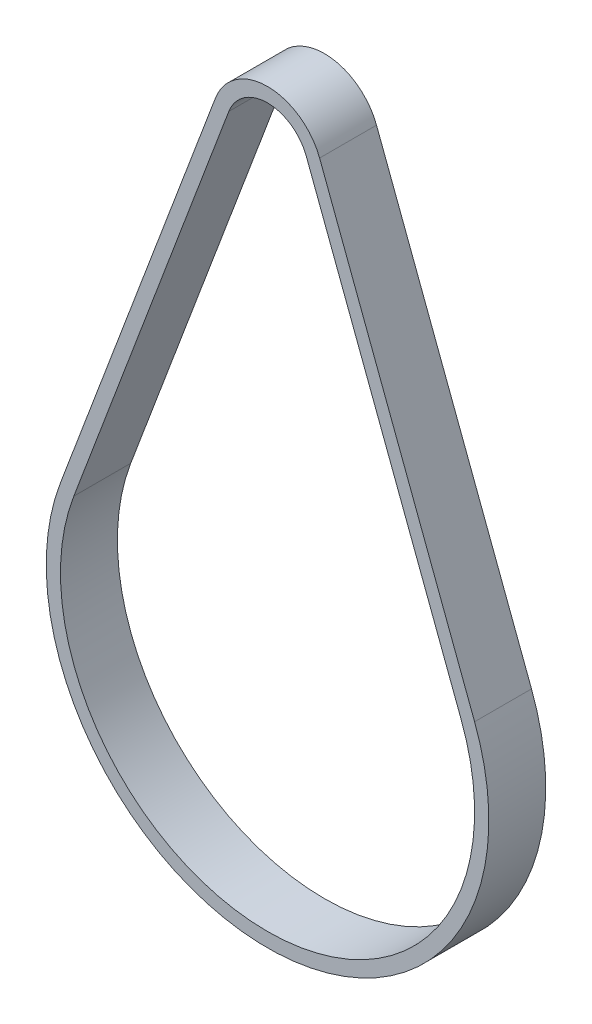
from build123d import *

# Parameters (mm, degrees)
SALIENTE_EXTRUIR1_DEPTH = 8


with BuildPart() as part:
    # Croquis1 → Saliente-Extruir1 (new body)
    with BuildSketch(Plane.XY):
        with BuildLine():
            Line((-7.316283488, 29.567625694), (-29.101406381, -28.155231387))
            ThreePointArc((-29.101406381, -28.155231387), (0, -70.243362618), (29.101406381, -28.155231387))
            Line((29.101406381, -28.155231387), (7.316283488, 29.567625694))
            ThreePointArc((7.316283488, 29.567625694), (0, 34.626394823), (-7.316283488, 29.567625694))
        make_face()
        with BuildLine():
            Line((-5.445111241, 28.86142854), (-27.230234133, -28.86142854))
            ThreePointArc((-27.230234133, -28.86142854), (0, -68.243362618), (27.230234133, -28.86142854))
            Line((27.230234133, -28.86142854), (5.445111241, 28.86142854))
            ThreePointArc((5.445111241, 28.86142854), (0, 32.626394823), (-5.445111241, 28.86142854))
        make_face(mode=Mode.SUBTRACT)
    extrude(amount=SALIENTE_EXTRUIR1_DEPTH)


solid = part.part
